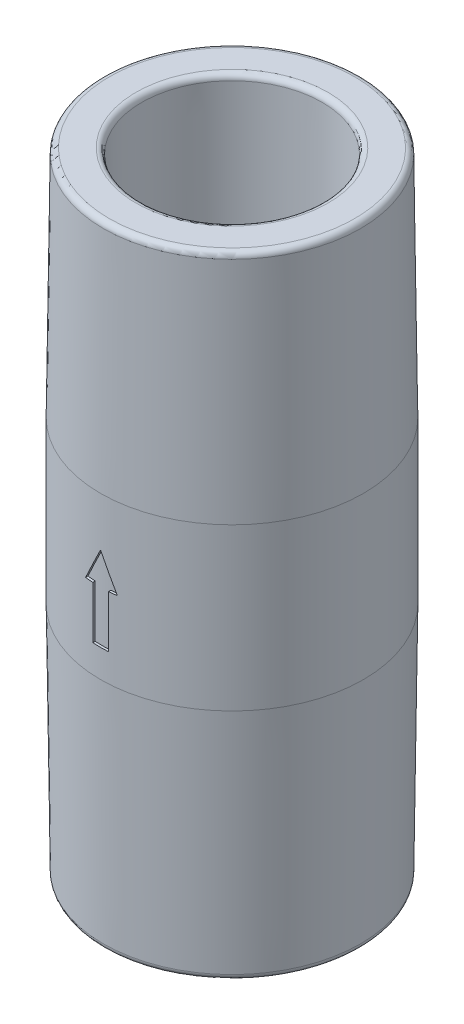
from build123d import *

# Parameters (mm, degrees)
BOSS_EXTRUDE4_DEPTH       = 12.859999996
FILLET1_R                 = 1
FILLET2_R                 = 0.25
FILLET3_R                 = 3
FILLET4_R                 = 0.5
CUT_EXTRUDE7_REACH        = 58.495
CUT_EXTRUDE7_START_RADIUS = 11.25
CUT_EXTRUDE7_END_RADIUS   = 11.25


with BuildPart() as part:
    # Sketch1 → Revolve1 (revolve)
    with BuildSketch(Plane(origin=(0, 0, 0), x_dir=(0, 0, -1), z_dir=(1, 0, 0)), mode=Mode.PRIVATE) as revolve1_sk:
        Polygon((7.725, 54), (7.55, 38.771909976), (10, 32.871909976), (10, 29.611909976), (8, 29.611909976), (8, 16.751909976), (7.41, 15.73), (7.725, 0), (11, 0), (11.25, 20.2), (11.25, 34), (11, 54), align=None)
    revolve(revolve1_sk.sketch.rotate(Axis((0, 25.776699029, 0), (0, -1, 0)), 180), axis=Axis((0, 25.776699029, 0), (0, -1, 0)))

    # Sketch2 → Boss-Extrude4 (add)
    with BuildSketch(Plane(origin=(0, 16.75190998, 0), x_dir=(1, 0, 0), z_dir=(0, 1, 0))):
        with BuildLine():
            Line((4.062019202, -0.75), (7.395099729, -0.75))
            ThreePointArc((7.395099729, -0.75), (7.776981037, -0.927251388), (7.888106377, -1.333333333))
            ThreePointArc((7.888106377, -1.333333333), (8, 0), (7.888106377, 1.333333333))
            ThreePointArc((7.888106377, 1.333333333), (7.776981037, 0.927251388), (7.395099729, 0.75))
            Line((7.395099729, 0.75), (4.062019202, 0.75))
            ThreePointArc((4.062019202, 0.75), (3.764974939, 0.847800167), (3.58413459, 1.102941176))
            ThreePointArc((3.58413459, 1.102941176), (3.247595264, 1.875), (2.747242373, 2.552481018))
            ThreePointArc((2.747242373, 2.552481018), (2.616703951, 2.836663859), (2.680528654, 3.14281182))
            Line((2.680528654, 3.14281182), (4.347068917, 6.029344229))
            ThreePointArc((4.347068917, 6.029344229), (4.691513776, 6.271437449), (5.098753727, 6.164633844))
            ThreePointArc((5.098753727, 6.164633844), (4, 6.92820323), (2.78935265, 7.497967177))
            ThreePointArc((2.78935265, 7.497967177), (3.085467261, 7.198688837), (3.048030812, 6.779344229))
            Line((3.048030812, 6.779344229), (1.381490548, 3.89281182))
            ThreePointArc((1.381490548, 3.89281182), (1.148270988, 3.684464026), (0.836892217, 3.655422194))
            ThreePointArc((0.836892217, 3.655422194), (0, 3.75), (-0.836892217, 3.655422194))
            ThreePointArc((-0.836892217, 3.655422194), (-1.148270988, 3.684464026), (-1.381490548, 3.89281182))
            Line((-1.381490548, 3.89281182), (-3.048030812, 6.779344229))
            ThreePointArc((-3.048030812, 6.779344229), (-3.085467261, 7.198688837), (-2.78935265, 7.497967177))
            ThreePointArc((-2.78935265, 7.497967177), (-4, 6.92820323), (-5.098753727, 6.164633844))
            ThreePointArc((-5.098753727, 6.164633844), (-4.691513776, 6.271437449), (-4.347068917, 6.029344229))
            Line((-4.347068917, 6.029344229), (-2.680528654, 3.14281182))
            ThreePointArc((-2.680528654, 3.14281182), (-2.616703951, 2.836663859), (-2.747242373, 2.552481018))
            ThreePointArc((-2.747242373, 2.552481018), (-3.247595264, 1.875), (-3.58413459, 1.102941176))
            ThreePointArc((-3.58413459, 1.102941176), (-3.764974939, 0.847800167), (-4.062019202, 0.75))
            Line((-4.062019202, 0.75), (-7.395099729, 0.75))
            ThreePointArc((-7.395099729, 0.75), (-7.776981037, 0.927251388), (-7.888106377, 1.333333333))
            ThreePointArc((-7.888106377, 1.333333333), (-8, 0), (-7.888106377, -1.333333333))
            ThreePointArc((-7.888106377, -1.333333333), (-7.776981037, -0.927251388), (-7.395099729, -0.75))
            Line((-7.395099729, -0.75), (-4.062019202, -0.75))
            ThreePointArc((-4.062019202, -0.75), (-3.764974939, -0.847800167), (-3.58413459, -1.102941176))
            ThreePointArc((-3.58413459, -1.102941176), (-3.247595264, -1.875), (-2.747242373, -2.552481018))
            ThreePointArc((-2.747242373, -2.552481018), (-2.616703951, -2.836663859), (-2.680528654, -3.14281182))
            Line((-2.680528654, -3.14281182), (-4.347068917, -6.029344229))
            ThreePointArc((-4.347068917, -6.029344229), (-4.691513776, -6.271437449), (-5.098753727, -6.164633844))
            ThreePointArc((-5.098753727, -6.164633844), (-4, -6.92820323), (-2.78935265, -7.497967177))
            ThreePointArc((-2.78935265, -7.497967177), (-3.085467261, -7.198688837), (-3.048030812, -6.779344229))
            Line((-3.048030812, -6.779344229), (-1.381490548, -3.89281182))
            ThreePointArc((-1.381490548, -3.89281182), (-1.148270988, -3.684464026), (-0.836892217, -3.655422194))
            ThreePointArc((-0.836892217, -3.655422194), (0, -3.75), (0.836892217, -3.655422194))
            ThreePointArc((0.836892217, -3.655422194), (1.148270988, -3.684464026), (1.381490548, -3.89281182))
            Line((1.381490548, -3.89281182), (3.048030812, -6.779344229))
            ThreePointArc((3.048030812, -6.779344229), (3.085467261, -7.198688837), (2.78935265, -7.497967177))
            ThreePointArc((2.78935265, -7.497967177), (4, -6.92820323), (5.098753727, -6.164633844))
            ThreePointArc((5.098753727, -6.164633844), (4.691513776, -6.271437449), (4.347068917, -6.029344229))
            Line((4.347068917, -6.029344229), (2.680528654, -3.14281182))
            ThreePointArc((2.680528654, -3.14281182), (2.616703951, -2.836663859), (2.747242373, -2.552481018))
            ThreePointArc((2.747242373, -2.552481018), (3.247595264, -1.875), (3.58413459, -1.102941176))
            ThreePointArc((3.58413459, -1.102941176), (3.764974939, -0.847800167), (4.062019202, -0.75))
        make_face()
    extrude(amount=BOSS_EXTRUDE4_DEPTH)

    # Sketch3 → Cut-Revolve1 (revolve, cut)
    with BuildSketch(Plane.XY, mode=Mode.PRIVATE) as cut_revolve1_sk:
        with BuildLine():
            Line((-2.6, 26.111909976), (-8, 16.75190998))
            Line((-8, 16.75190998), (0, 16.751909976))
            Line((0, 16.751909976), (0, 27.611909976))
            ThreePointArc((0, 27.611909976), (-1.501219512, 27.210690464), (-2.6, 26.111909976))
        make_face()
    revolve(cut_revolve1_sk.sketch.rotate(Axis((0, 0, 0), (0, 1, 0)), 270), axis=Axis((0, 0, 0), (0, 1, 0)), mode=Mode.SUBTRACT)

    # Sketch4 → Revolve2 (revolve)
    with BuildSketch(Plane.XY, mode=Mode.PRIVATE) as revolve2_sk:
        with BuildLine():
            Line((-2.5, 29.611909976), (-2.5, 31.111909976))
            Line((-2.5, 31.111909976), (-3.25, 31.111909976))
            ThreePointArc((-3.25, 31.111909976), (-2.298097039, 33.410007015), (0, 34.361909976))
            Line((0, 34.361909976), (0, 29.611909976))
            Line((0, 29.611909976), (-2.5, 29.611909976))
        make_face()
    revolve(revolve2_sk.sketch.rotate(Axis((0, 0, 0), (0, 1, 0)), 270), axis=Axis((0, 0, 0), (0, 1, 0)))

    # Fillet1
    fillet1_edges = [part.edges().sort_by_distance(p)[0] for p in [
        (0, 15.73, -7.41),
    ]]
    fillet(fillet1_edges, radius=FILLET1_R)

    # Fillet2
    fillet2_edges = [part.edges().sort_by_distance(p)[0] for p in [
        (0, 29.611909976, -10),
        (0, 29.611909976, 2.5),
        (0, 31.111909976, 2.5),
    ]]
    fillet(fillet2_edges, radius=FILLET2_R)

    # Fillet3
    fillet3_edges = [part.edges().sort_by_distance(p)[0] for p in [
        (0, 32.871909976, -10),
        (0, 38.771909976, -7.55),
    ]]
    fillet(fillet3_edges, radius=FILLET3_R)

    # Fillet4
    fillet4_edges = [part.edges().sort_by_distance(p)[0] for p in [
        (0, 0, -7.725),
        (0, 54, -7.725),
        (0, 54, -11),
        (0, 0, -11),
    ]]
    fillet(fillet4_edges, radius=FILLET4_R)

    # Cut-Extrude7: from a cylinder face, 58.495 long prism both ways, kept between that surface and its translate by the depth
    cut_extrude7_start = Plane(origin=(0, 26.031974, 0), z_dir=(0, 1, 0)) * Cylinder(CUT_EXTRUDE7_START_RADIUS, 140.49, mode=Mode.PRIVATE)
    cut_extrude7_end = Plane(origin=(0, 26.031974, -0.2), z_dir=(0, 1, 0)) * Cylinder(CUT_EXTRUDE7_END_RADIUS, 140.49, mode=Mode.PRIVATE)
    # Sketch7 → Cut-Extrude7 (cut, from a surface)
    with BuildSketch(Plane.XY, mode=Mode.PRIVATE) as cut_extrude7_sk1:
        Polygon((0, 29.816025526), (1.360306739, 27.057772803), (0.676362838, 27.057772803), (0.676362838, 22.590580194), (-0.676362838, 22.590580194), (-0.676362838, 27.057772803), (-1.360306739, 27.057772803), align=None)
    cut_extrude7_tool1 = extrude(cut_extrude7_sk1.sketch, amount=CUT_EXTRUDE7_REACH, both=True, mode=Mode.PRIVATE)
    cut_extrude7 = ((cut_extrude7_tool1 & cut_extrude7_start) - cut_extrude7_end).solids().sort_by_distance((0, 26.031974, 11.108728))[0]
    add(cut_extrude7, mode=Mode.SUBTRACT)

    # Mirror1: Cut-Extrude7 across plane
    add(cut_extrude7.mirror(Plane.XY), mode=Mode.SUBTRACT)


solid = part.part
